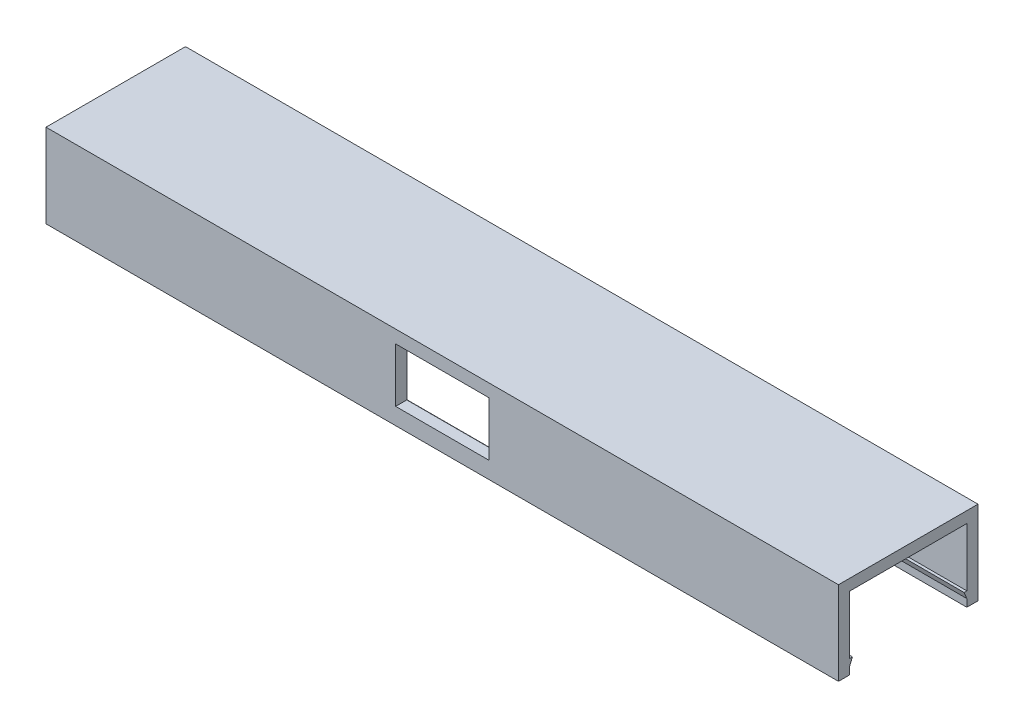
from build123d import *

# Parameters (mm, degrees)
CROQUIS1_W              = 142
CROQUIS1_H              = 20.7
CROQUIS1_H_2            = 2.15
SALIENTE_EXTRUIR1_DEPTH = 15
CROQUIS2_W              = 21
CROQUIS2_H              = 13
CORTAR_EXTRUIR1_DEPTH   = 230
SALIENTE_EXTRUIR4_DEPTH = 142
CROQUIS12_W             = 16.7
CROQUIS12_H             = 9.7
CORTAR_EXTRUIR2_DEPTH   = 50


with BuildPart() as part:
    # Croquis1 → Saliente-Extruir1 (new body)
    with BuildSketch(Plane(origin=(0, 0, 0), x_dir=(1, 0, 0), z_dir=(0, 1, 0))):
        Rectangle(CROQUIS1_W, CROQUIS1_H)
        with Locations((0, 11.425)):
            Rectangle(CROQUIS1_W, CROQUIS1_H_2)
        with Locations((0, -11.425)):
            Rectangle(CROQUIS1_W, CROQUIS1_H_2)
    extrude(amount=SALIENTE_EXTRUIR1_DEPTH)

    # Croquis2 → Cortar-Extruir1 (cut)
    with BuildSketch(Plane.ZY.offset(71)):
        with Locations((0, 6.5)):
            Rectangle(CROQUIS2_W, CROQUIS2_H)
    extrude(amount=-CORTAR_EXTRUIR1_DEPTH, mode=Mode.SUBTRACT)

    # Croquis11 → Saliente-Extruir4 (add)
    with BuildSketch(Plane.ZY.offset(71)):
        Polygon((-10.5, 1.35), (-10.5, 2.55), (-10, 2.55), align=None)
        Polygon((10, 2.55), (10.5, 1.35), (10.5, 2.55), align=None)
    extrude(amount=-SALIENTE_EXTRUIR4_DEPTH)

    # Croquis12 → Cortar-Extruir2 (cut)
    with BuildSketch(Plane.XY.offset(12.5)):
        with Locations((0, 7.85)):
            Rectangle(CROQUIS12_W, CROQUIS12_H)
    extrude(amount=-CORTAR_EXTRUIR2_DEPTH, mode=Mode.SUBTRACT)


solid = part.part
